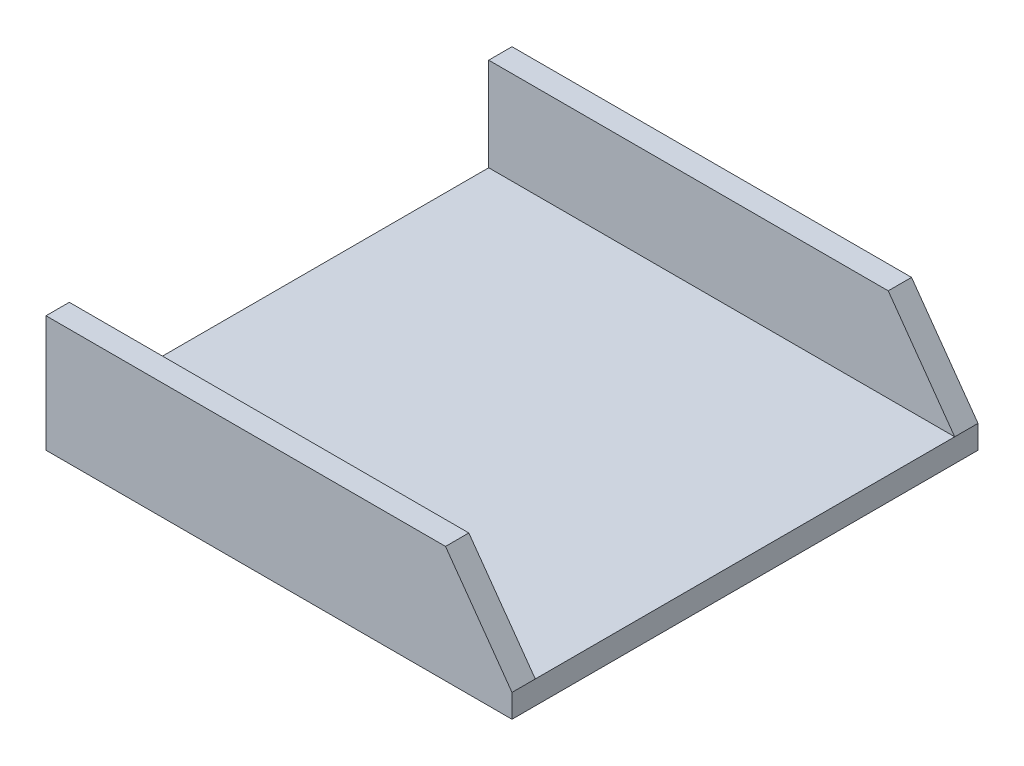
from build123d import *

# Parameters (mm, degrees)
BOSS_EXTRUDE1_DEPTH     = 600
CUT_EXTRUDE1_DEPTH      = 600
CUT_EXTRUDE1_DEPTH_BACK = 600


with BuildPart() as part:
    # Sketch1 → Boss-Extrude1 (new body)
    with BuildSketch(Plane(origin=(0, 0, 0), x_dir=(0, 0, -1), z_dir=(1, 0, 0))):
        Polygon((30, 150), (30, 30), (570, 30), (570, 150), (600, 150), (600, 0), (0, 0), (0, 150), align=None)
    extrude(amount=BOSS_EXTRUDE1_DEPTH)

    # Sketch4 → Cut-Extrude1 (cut, two sides)
    with BuildSketch(Plane(origin=(0, 0, -30), x_dir=(-1, 0, 0), z_dir=(0, 0, -1))) as cut_extrude1_sk:
        Polygon((-600, 30), (-514.410107884, 150), (-600, 150), align=None)
    extrude(amount=CUT_EXTRUDE1_DEPTH, mode=Mode.SUBTRACT)
    extrude(cut_extrude1_sk.sketch, amount=-CUT_EXTRUDE1_DEPTH_BACK, mode=Mode.SUBTRACT)


solid = part.part
